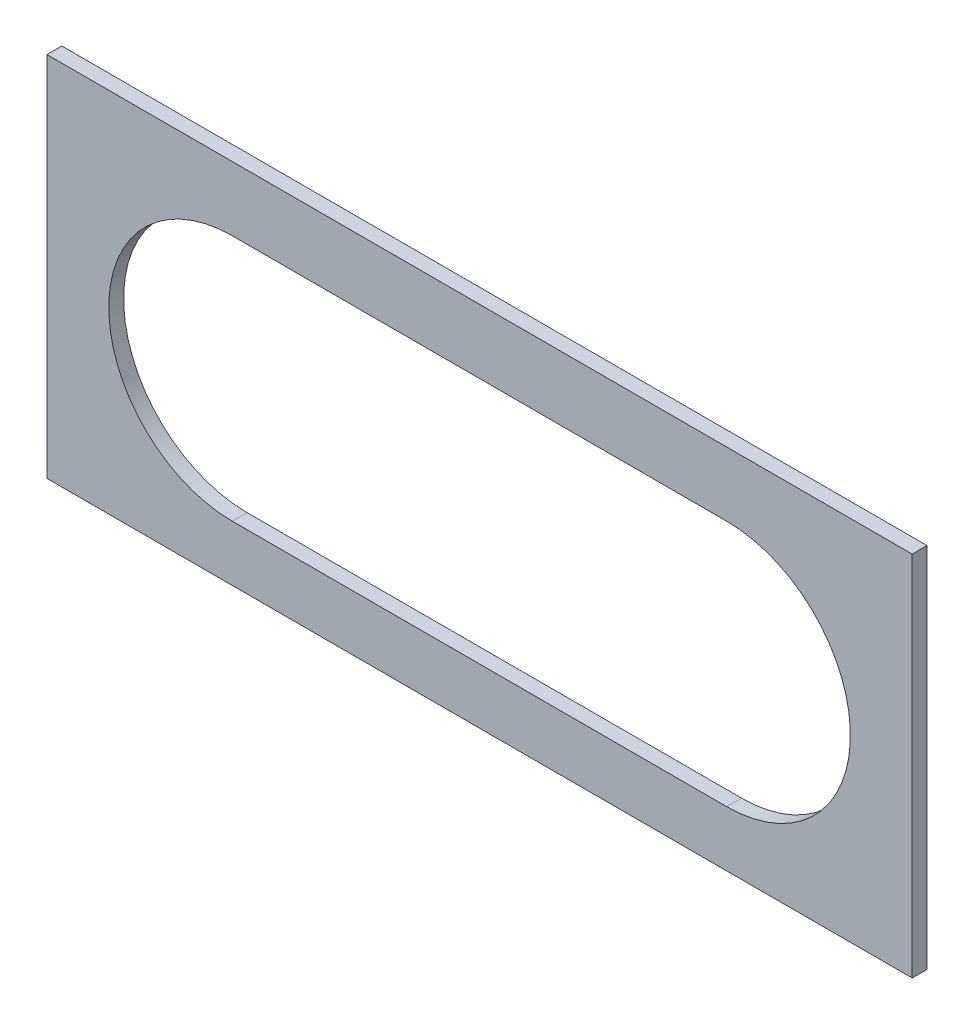
from build123d import *

# Parameters (mm, degrees)
ESQUISSE1_W        = 700
ESQUISSE1_H        = 297
BOSS_EXTRU_1_DEPTH = 12


with BuildPart() as part:
    # Esquisse1 → Boss.-Extru.1 (new body)
    with BuildSketch(Plane.XY):
        Rectangle(ESQUISSE1_W, ESQUISSE1_H)
        with BuildLine():
            Line((-200, 96.5), (200, 96.5))
            ThreePointArc((200, 96.5), (300, -3.5), (200, -103.5))
            Line((200, -103.5), (-200, -103.5))
            ThreePointArc((-200, -103.5), (-300, -3.5), (-200, 96.5))
        make_face(mode=Mode.SUBTRACT)
    extrude(amount=BOSS_EXTRU_1_DEPTH)


solid = part.part
